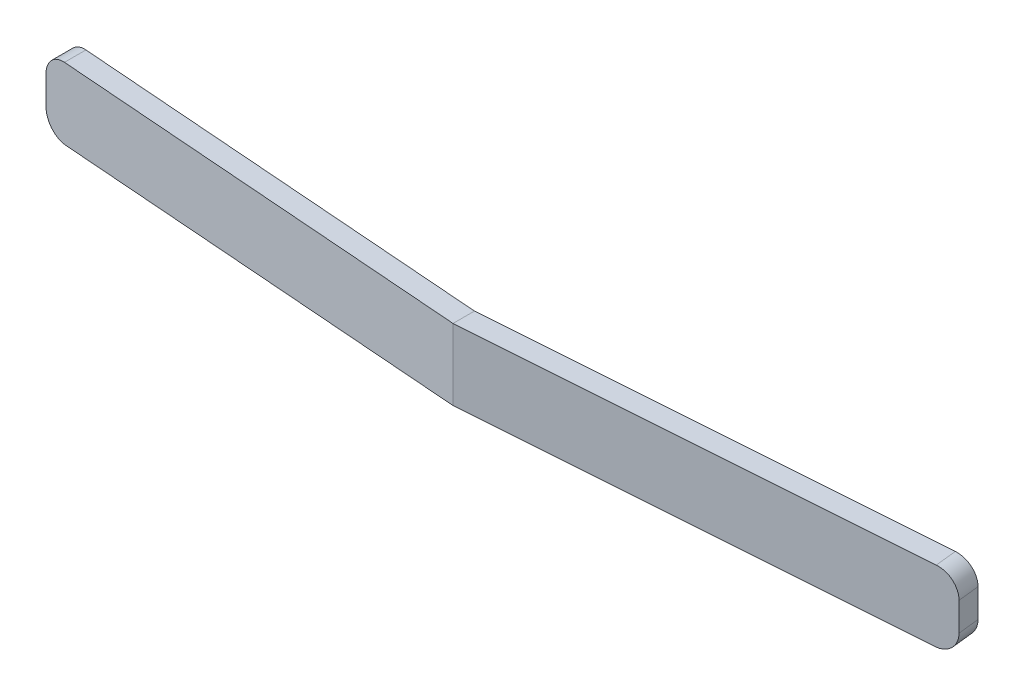
from build123d import *

# Parameters (mm, degrees)
BOSS_EXTRUDE2_DEPTH     = 20
CUT_EXTRUDE1_DEPTH      = 4.016802691
CUT_EXTRUDE1_DEPTH_BACK = 7.783143762
FILLET1_R               = 3


with BuildPart() as part:
    # Sketch2 → Boss-Extrude2 (new body)
    with BuildSketch(Plane(origin=(0, 0, 0), x_dir=(1, 0, 0), z_dir=(0, 1, 0))):
        Polygon((0, 0), (-64, 6.783143762), (-64, 3.766341072), (0, -3.016802691), (64.316188922, 3.799852867), (64, 6.783143762), align=None)
    extrude(amount=BOSS_EXTRUDE2_DEPTH)

    # Sketch3 → Cut-Extrude1 (cut, two sides)
    with BuildSketch(Plane.XY) as cut_extrude1_sk:
        Polygon((0, 7.890942367), (-64, 5.798881402), (-64, 0), (64.316188922, 0), (64.316188922, 5.838536205), align=None)
        Polygon((-64, 20), (-64, 15.798881402), (0, 17.890942367), (64.316188922, 15.838536205), (64.316188922, 20), align=None)
    extrude(amount=CUT_EXTRUDE1_DEPTH, mode=Mode.SUBTRACT)
    extrude(cut_extrude1_sk.sketch, amount=-CUT_EXTRUDE1_DEPTH_BACK, mode=Mode.SUBTRACT)

    # Fillet1
    fillet1_edges = [part.edges().sort_by_distance(p)[0] for p in [
        (64.158094461, 15.843581188, -5.291498315),
        (64.158094461, 5.843581188, -5.291498315),
        (-64, 5.798881402, -5.274742417),
        (-64, 15.798881402, -5.274742417),
    ]]
    fillet(fillet1_edges, radius=FILLET1_R)


solid = part.part
